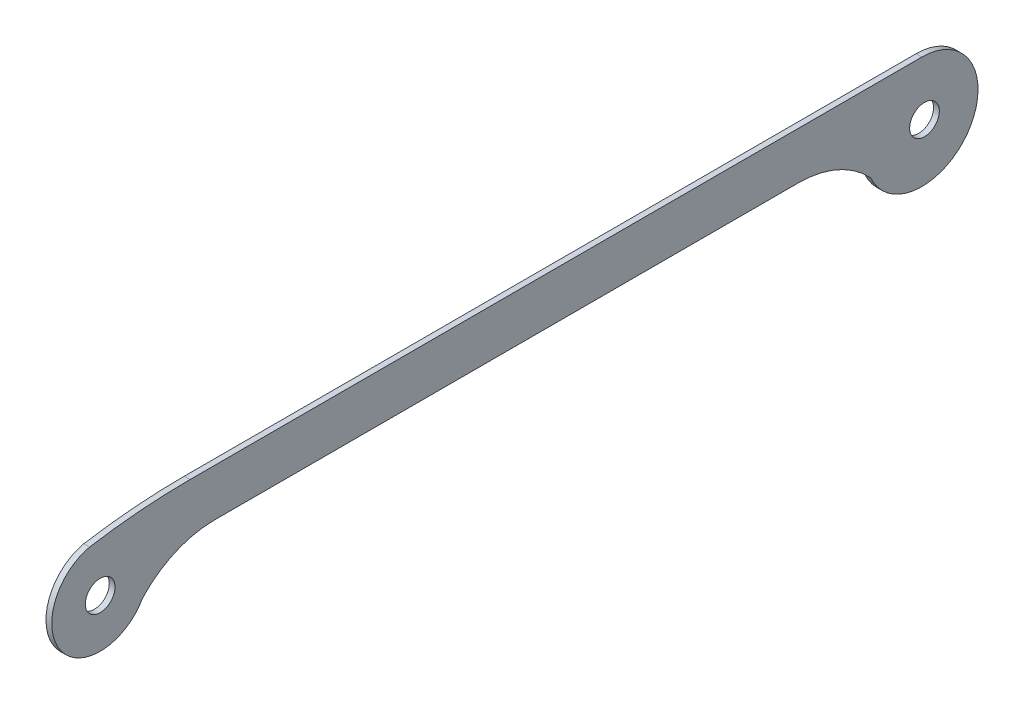
from build123d import *

# Parameters (mm, degrees)
SKETCH_1_R      = 3.85
EXTRUDE_1_DEPTH = 1.5


with BuildPart() as part:
    # 草圖1 → 填料-伸長1 (new body)
    with BuildSketch(Plane(origin=(0, 0, 0), x_dir=(0, 0, -1), z_dir=(1, 0, 0))):
        with BuildLine():
            Line((251.501318297, 74.382976373), (100.201901366, 74.382976373))
            ThreePointArc((100.201901366, 74.382976373), (89.968438713, 72.236892378), (81.459379698, 66.160269216))
            ThreePointArc((81.459379698, 66.160269216), (60.428444362, 64.718846971), (67.717817707, 84.498709848))
            ThreePointArc((67.717817707, 84.498709848), (80.697411325, 86.098517108), (93.764300282, 86.632976373))
            Line((93.764300282, 86.632976373), (249.095497945, 86.632976373))
            Line((249.095497945, 86.632976373), (283.552477777, 86.632976373))
            ThreePointArc((283.552477777, 86.632976373), (295.765347138, 64.159226657), (270.264218528, 66.138126331))
            Line((270.264218528, 66.138126331), (270.243839965, 66.160269216))
            ThreePointArc((270.243839965, 66.160269216), (261.734780949, 72.236892378), (251.501318297, 74.382976373))
        make_face()
        with Locations((70.477225092, 72.248709848)):
            Circle(SKETCH_1_R, mode=Mode.SUBTRACT)
        with Locations((284.227225092, 72.248709848)):
            Circle(SKETCH_1_R, mode=Mode.SUBTRACT)
    extrude(amount=EXTRUDE_1_DEPTH)


solid = part.part
